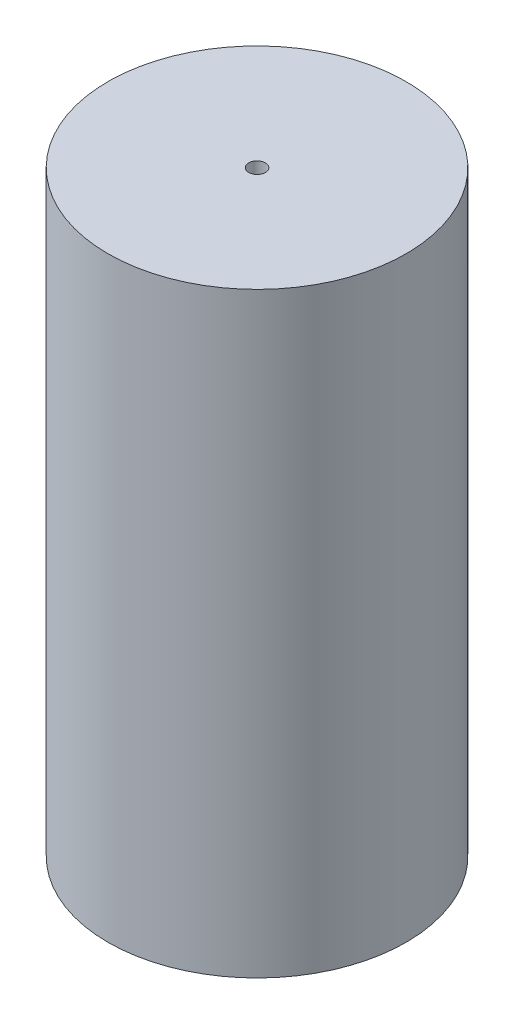
from build123d import *

# Parameters (mm, degrees)
SKETCH1_R           = 25
BOSS_EXTRUDE1_DEPTH = 100
SKETCH3_R           = 1.4
CUT_EXTRUDE3_DEPTH  = 20
SKETCH5_R           = 1.4
CUT_EXTRUDE4_DEPTH  = 20


with BuildPart() as part:
    # Sketch1 → Boss-Extrude1 (new body)
    with BuildSketch(Plane(origin=(0, 0, 0), x_dir=(1, 0, 0), z_dir=(0, 1, 0))):
        Circle(SKETCH1_R)
    extrude(amount=BOSS_EXTRUDE1_DEPTH)

    # Sketch3 → Cut-Extrude3 (cut)
    with BuildSketch(Plane(origin=(0, 100, 0), x_dir=(1, 0, 0), z_dir=(0, 1, 0))):
        Circle(SKETCH3_R)
    extrude(amount=-CUT_EXTRUDE3_DEPTH, mode=Mode.SUBTRACT)

    # Sketch5 → Cut-Extrude4 (cut)
    with BuildSketch(Plane.XZ):
        Circle(SKETCH5_R)
    extrude(amount=-CUT_EXTRUDE4_DEPTH, mode=Mode.SUBTRACT)


solid = part.part
